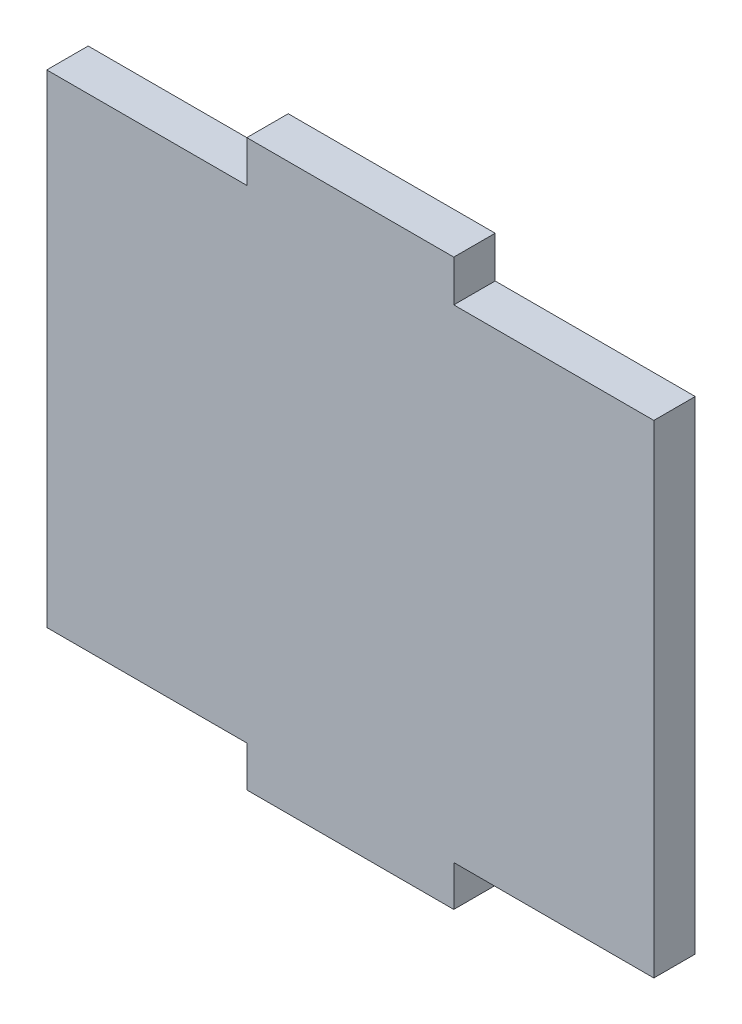
from build123d import *

# Parameters (mm, degrees)
EXTRUDE_1_DEPTH = 3


with BuildPart() as part:
    # 草图1 → 凸台-拉伸1 (new body)
    with BuildSketch(Plane.XY):
        Polygon((-7.5, 20.5), (7.5, 20.5), (7.5, 17.5), (22, 17.5), (22, -17.5), (7.5, -17.5), (7.5, -20.447374488), (-7.5, -20.447374488), (-7.5, -17.5), (-22, -17.5), (-22, 17.5), (-7.5, 17.5), align=None)
    extrude(amount=EXTRUDE_1_DEPTH)


solid = part.part
